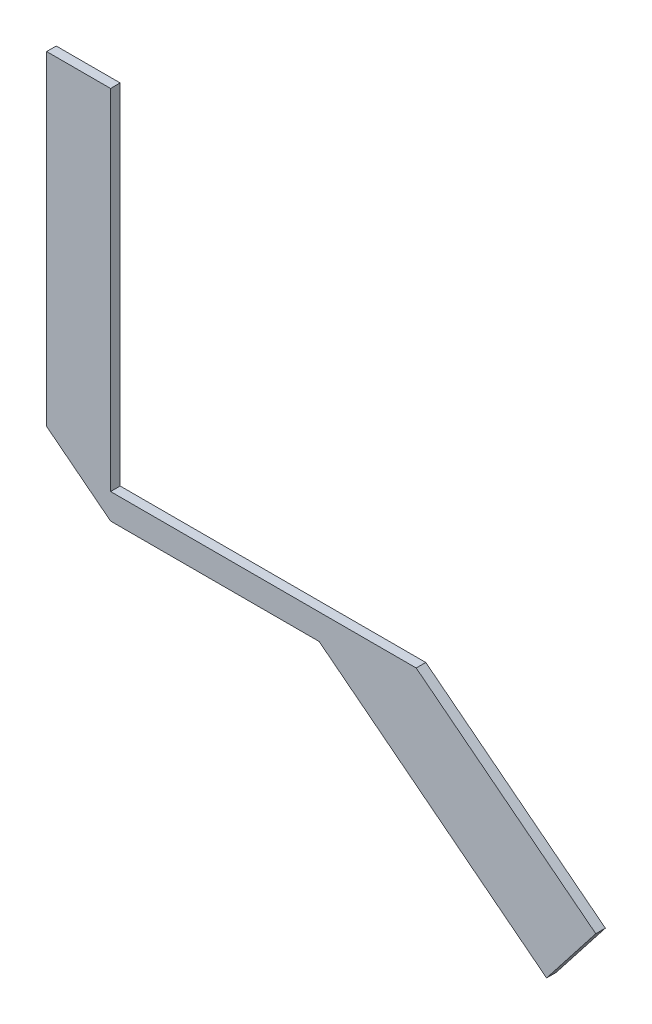
from build123d import *

# Parameters (mm, degrees)
BOSS_EXTRUDE1_DEPTH = 3


with BuildPart() as part:
    # Sketch3 → Boss-Extrude1 (new body)
    with BuildSketch(Plane.XY.offset(-2)):
        Polygon((-331.826668729, 452.47886283), (-275.647209147, 408.586658554), (-291.038746031, 388.886389714), (-362.193866809, 444.47886283), (-427.432442284, 444.47886283), (-447.432442284, 460.10457536), (-447.432442284, 561.679955314), (-427.432442284, 561.679955314), (-427.432442284, 452.47886283), align=None)
    extrude(amount=-BOSS_EXTRUDE1_DEPTH)


solid = part.part
